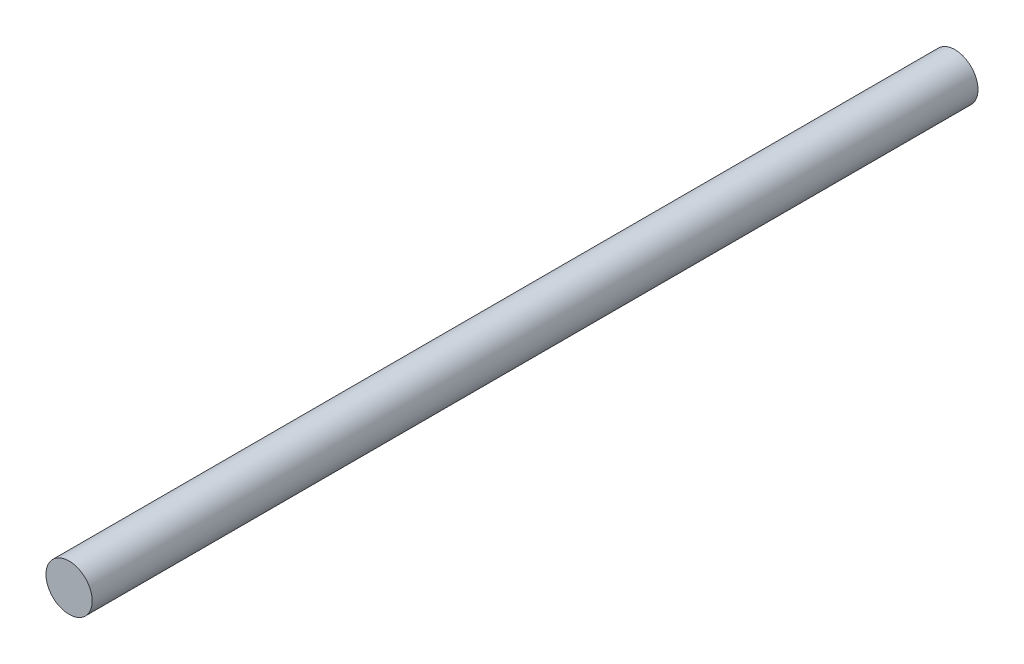
from build123d import *

# Parameters (mm, degrees)
SKETCH2_R           = 3.175
BOSS_EXTRUDE1_DEPTH = 121.60504


with BuildPart() as part:
    # Sketch2 → Boss-Extrude1 (new body)
    with BuildSketch(Plane.XY.offset(106.36504)):
        with Locations((-26.924, 0)):
            Circle(SKETCH2_R)
    extrude(amount=-BOSS_EXTRUDE1_DEPTH)


solid = part.part
